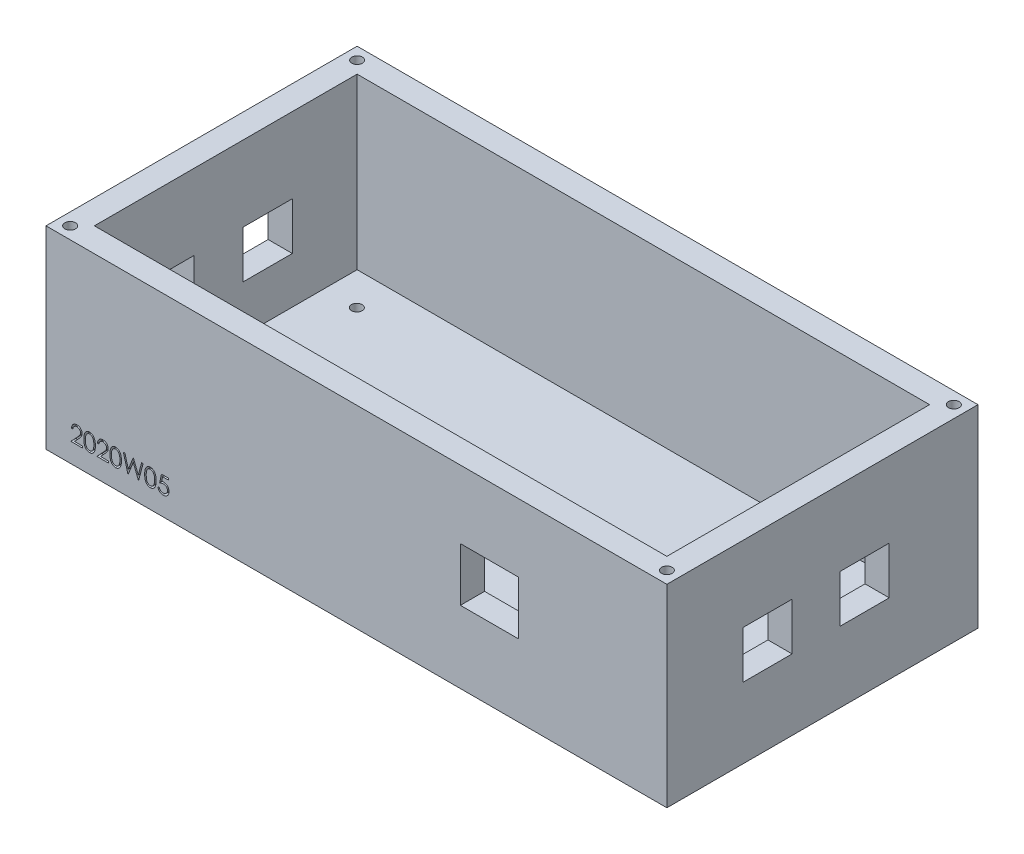
from build123d import *

# Parameters (mm, degrees)
SKETCH1_W           = 128.3
SKETCH1_H           = 64.29
BOSS_EXTRUDE1_DEPTH = 5
SKETCH2_W           = 128.3
SKETCH2_H           = 64.29
SKETCH2_W_2         = 118.3
SKETCH2_H_2         = 54.29
BOSS_EXTRUDE2_DEPTH = 35
SKETCH3_R           = 1.1
CUT_EXTRUDE1_DEPTH  = 6
SKETCH4_R           = 1.1
CUT_EXTRUDE2_DEPTH  = 5
SKETCH5_W           = 10.16
SKETCH5_H           = 9.8
CUT_EXTRUDE3_DEPTH  = 61
SKETCH6_W           = 10.16
SKETCH6_H           = 9.8
CUT_EXTRUDE4_DEPTH  = 61
SKETCH7_W           = 12.03
SKETCH7_H           = 11.05
CUT_EXTRUDE5_DEPTH  = 35
CUT_EXTRUDE6_DEPTH  = 1


with BuildPart() as part:
    # Sketch1 → Boss-Extrude1 (new body)
    with BuildSketch(Plane(origin=(0, 0, 0), x_dir=(1, 0, 0), z_dir=(0, 1, 0))):
        with Locations((-64.15, 32.145)):
            Rectangle(SKETCH1_W, SKETCH1_H)
    extrude(amount=BOSS_EXTRUDE1_DEPTH)

    # Sketch2 → Boss-Extrude2 (add)
    with BuildSketch(Plane(origin=(0, 5, 0), x_dir=(1, 0, 0), z_dir=(0, 1, 0))):
        with Locations((-64.15, 32.145)):
            Rectangle(SKETCH2_W, SKETCH2_H)
        with Locations((-64.15, 32.145)):
            Rectangle(SKETCH2_W_2, SKETCH2_H_2, mode=Mode.SUBTRACT)
    extrude(amount=BOSS_EXTRUDE2_DEPTH)

    # Sketch3 → Cut-Extrude1 (cut, through all)
    with BuildSketch(Plane(origin=(0, 5, 0), x_dir=(1, 0, 0), z_dir=(0, 1, 0))):
        with Locations((-116.54, 52.465)):
            Circle(SKETCH3_R)
        with Locations((-11.76, 52.465)):
            Circle(SKETCH3_R)
        with Locations((-11.76, 11.825)):
            Circle(SKETCH3_R)
        with Locations((-116.54, 11.825)):
            Circle(SKETCH3_R)
    extrude(amount=-CUT_EXTRUDE1_DEPTH, mode=Mode.SUBTRACT)

    # Sketch4 → Cut-Extrude2 (cut)
    with BuildSketch(Plane(origin=(0, 40, 0), x_dir=(1, 0, 0), z_dir=(0, 1, 0))):
        with Locations((-125.8, 61.79)):
            Circle(SKETCH4_R)
        with Locations((-125.8, 2.5)):
            Circle(SKETCH4_R)
        with Locations((-2.5, 2.5)):
            Circle(SKETCH4_R)
        with Locations((-2.5, 61.79)):
            Circle(SKETCH4_R)
    extrude(amount=-CUT_EXTRUDE2_DEPTH, mode=Mode.SUBTRACT)

    # Sketch5 → Cut-Extrude3 (cut)
    with BuildSketch(Plane.ZY.offset(128.3)):
        with Locations((-40.82, 19.5)):
            Rectangle(SKETCH5_W, SKETCH5_H)
        with Locations((-20.5, 19.5)):
            Rectangle(SKETCH5_W, SKETCH5_H)
    extrude(amount=-CUT_EXTRUDE3_DEPTH, mode=Mode.SUBTRACT)

    # Sketch6 → Cut-Extrude4 (cut)
    with BuildSketch(Plane(origin=(0, 0, 0), x_dir=(0, 0, -1), z_dir=(1, 0, 0))):
        with Locations((20.8, 19.5)):
            Rectangle(SKETCH6_W, SKETCH6_H)
        with Locations((40.87, 19.5)):
            Rectangle(SKETCH6_W, SKETCH6_H)
    extrude(amount=-CUT_EXTRUDE4_DEPTH, mode=Mode.SUBTRACT)

    # Sketch7 → Cut-Extrude5 (cut)
    with BuildSketch(Plane.XY):
        with Locations((-36.655, 20.425)):
            Rectangle(SKETCH7_W, SKETCH7_H)
    extrude(amount=-CUT_EXTRUDE5_DEPTH, mode=Mode.SUBTRACT)

    # Sketch8 → Cut-Extrude6 (cut)
    with BuildSketch(Plane.XY):
        with BuildLine():
            Line((-122.716666667, 6.423076923), (-123.030769231, 6.423076923))
            add(Edge.make_bspline(
                [(-123.030769231, 6.423076923), (-123.028722078, 6.464747811), (-123.024701524, 6.546588325), (-123.005873234, 6.665912232), (-122.978932357, 6.779967031), (-122.940840903, 6.887836945), (-122.893534625, 6.990475752), (-122.836804598, 7.087475767), (-122.769610748, 7.178466956), (-122.693404014, 7.262605799), (-122.610635374, 7.33979337), (-122.521329435, 7.406448613), (-122.427484408, 7.462766284), (-122.329385009, 7.509847526), (-122.225924445, 7.545187372), (-122.118041587, 7.571409012), (-122.005262451, 7.587185357), (-121.928422429, 7.588881143), (-121.889342949, 7.58974359)],
                knots=[0, 0, 0, 0, 0.000125083, 0.00024566, 0.000361805, 0.000476223, 0.000588214, 0.000700404, 0.000812728, 0.00092691, 0.001040529, 0.001151727, 0.001260545, 0.001368429, 0.001477521, 0.001587884, 0.001701119, 0.00181831, 0.00181831, 0.00181831, 0.00181831], degree=3))
            add(Edge.make_bspline(
                [(-121.889342949, 7.58974359), (-121.850964875, 7.588845133), (-121.77555333, 7.587079698), (-121.665491316, 7.571918669), (-121.560714021, 7.548173078), (-121.461426255, 7.514857661), (-121.36842019, 7.470073234), (-121.280997145, 7.416275695), (-121.198116335, 7.354055864), (-121.123509551, 7.28080205), (-121.055001472, 7.202599666), (-120.995899217, 7.119111762), (-120.945286053, 7.032882477), (-120.903098373, 6.943254275), (-120.872042234, 6.849383247), (-120.848464026, 6.752636044), (-120.835136613, 6.652011233), (-120.833091189, 6.583904677), (-120.832051282, 6.549278846)],
                knots=[0, 0, 0, 0, 0.000115089, 0.000226145, 0.000332614, 0.000437044, 0.000539592, 0.000641561, 0.000744629, 0.00084975, 0.000954621, 0.001056175, 0.001156101, 0.001254284, 0.001352726, 0.001452208, 0.001552655, 0.001656537, 0.001656537, 0.001656537, 0.001656537], degree=3))
            add(Edge.make_bspline(
                [(-120.832051282, 6.549278846), (-120.833744545, 6.500531012), (-120.837101356, 6.403890798), (-120.865815733, 6.261875935), (-120.910662244, 6.124282516), (-120.964659601, 6.013545214), (-121.019132045, 5.92431172), (-121.068219552, 5.850843015), (-121.125684363, 5.771737547), (-121.192362861, 5.68726021), (-121.266875734, 5.596749304), (-121.349897897, 5.500259509), (-121.442021379, 5.398787739), (-121.50667988, 5.329482138), (-121.540184295, 5.293569712)],
                knots=[0, 0, 0, 0, 0.000146118, 0.000289672, 0.0004329, 0.00057934, 0.000657978, 0.000746456, 0.000844345, 0.000951219, 0.001069268, 0.00119604, 0.001333047, 0.001480391, 0.001480391, 0.001480391, 0.001480391], degree=3))
            Line((-121.540184295, 5.293569712), (-122.415885417, 4.358974359))
            Line((-122.415885417, 4.358974359), (-120.787179487, 4.358974359))
            Line((-120.787179487, 4.358974359), (-120.787179487, 4))
            Line((-120.787179487, 4), (-123.165384615, 4))
            Line((-123.165384615, 4), (-121.808012821, 5.448517628))
            add(Edge.make_bspline(
                [(-121.808012821, 5.448517628), (-121.774964934, 5.483015935), (-121.711486707, 5.549280121), (-121.62170413, 5.646023081), (-121.541065141, 5.735772622), (-121.469047749, 5.818359171), (-121.407214243, 5.894990738), (-121.352342011, 5.963185442), (-121.30837642, 6.025939892), (-121.260661025, 6.098680506), (-121.214447043, 6.187492823), (-121.174734687, 6.296026513), (-121.150519839, 6.407753765), (-121.147615003, 6.483255802), (-121.146153846, 6.521233974)],
                knots=[0, 0, 0, 0, 0.000143319, 0.000275286, 0.00039593, 0.000505287, 0.000603949, 0.000691331, 0.000767782, 0.00083371, 0.000952247, 0.001067137, 0.001179618, 0.001293462, 0.001293462, 0.001293462, 0.001293462], degree=3))
            add(Edge.make_bspline(
                [(-121.146153846, 6.521233974), (-121.146789588, 6.545115373), (-121.148042514, 6.592181023), (-121.159100212, 6.661186782), (-121.175810718, 6.727751596), (-121.199755976, 6.792080215), (-121.231362716, 6.853525867), (-121.269836096, 6.912163347), (-121.31422616, 6.968852313), (-121.365577429, 7.022005611), (-121.421988949, 7.070686816), (-121.481583198, 7.113810902), (-121.544633302, 7.149850012), (-121.610873425, 7.179393509), (-121.680118894, 7.202568891), (-121.752503639, 7.21862747), (-121.827827655, 7.228709954), (-121.879261151, 7.230074126), (-121.90546875, 7.230769231)],
                knots=[0, 0, 0, 0, 7.16e-05, 0.00014111, 0.00020913, 0.00027724, 0.000346538, 0.000415963, 0.000487357, 0.000562233, 0.000637292, 0.000710646, 0.000782564, 0.000854749, 0.000927915, 0.001001225, 0.001076884, 0.001155488, 0.001155488, 0.001155488, 0.001155488], degree=3))
            add(Edge.make_bspline(
                [(-121.90546875, 7.230769231), (-121.932839583, 7.230054199), (-121.986591379, 7.228649993), (-122.065510412, 7.218827329), (-122.140796189, 7.201881489), (-122.212638092, 7.178704814), (-122.281157678, 7.149246266), (-122.346021722, 7.112554521), (-122.407084611, 7.068771028), (-122.464461135, 7.019130471), (-122.517325114, 6.96386287), (-122.56377199, 6.902252907), (-122.604356004, 6.835425492), (-122.639765237, 6.763560941), (-122.668520927, 6.686007161), (-122.690494078, 6.603039456), (-122.707880925, 6.515018075), (-122.713689445, 6.45423299), (-122.716666667, 6.423076923)],
                knots=[0, 0, 0, 0, 8.2106e-05, 0.000161243, 0.000238127, 0.000313291, 0.000387401, 0.000461495, 0.000536397, 0.000612445, 0.000688819, 0.000765383, 0.000843422, 0.000923066, 0.001005373, 0.001091093, 0.001180334, 0.001274175, 0.001274175, 0.001274175, 0.001274175], degree=3))
        make_face()
        with BuildLine():
            add(Edge.make_bspline(
                [(-120.473076923, 5.748597756), (-120.472748905, 5.804695144), (-120.472111725, 5.913665128), (-120.465023304, 6.07244977), (-120.453247962, 6.221410059), (-120.437110589, 6.360553125), (-120.417472609, 6.48991489), (-120.391257122, 6.609149647), (-120.361444319, 6.718809254), (-120.326891874, 6.819251302), (-120.287904085, 6.911829005), (-120.245469824, 6.998254207), (-120.197905029, 7.078396139), (-120.147928116, 7.153533929), (-120.093516045, 7.222437624), (-120.036217254, 7.286080287), (-119.973795378, 7.342991037), (-119.90837237, 7.394837339), (-119.839355905, 7.440286811), (-119.768713239, 7.48031955), (-119.695958133, 7.514519417), (-119.620891951, 7.541409853), (-119.544189393, 7.5636207), (-119.465582326, 7.578809647), (-119.384940962, 7.588366556), (-119.330509527, 7.589280224), (-119.302904647, 7.58974359)],
                knots=[0, 0, 0, 0, 0.000168282, 0.000326891, 0.000476705, 0.00061646, 0.000747059, 0.00086904, 0.000982494, 0.001087814, 0.001187428, 0.001283689, 0.001376399, 0.001466822, 0.001554203, 0.001639568, 0.001723424, 0.001807301, 0.001889751, 0.001971063, 0.002050735, 0.002130583, 0.002210036, 0.002290062, 0.002370508, 0.002453288, 0.002453288, 0.002453288, 0.002453288], degree=3))
            add(Edge.make_bspline(
                [(-119.302904647, 7.58974359), (-119.275069169, 7.589255775), (-119.21971316, 7.588285664), (-119.137872785, 7.578961721), (-119.057923103, 7.563490598), (-118.980204964, 7.541569623), (-118.904079978, 7.514373947), (-118.83014357, 7.48028683), (-118.757936489, 7.440607962), (-118.688606201, 7.393984085), (-118.621391586, 7.342001809), (-118.557943623, 7.28323914), (-118.498256537, 7.218289421), (-118.441581232, 7.147847557), (-118.389525634, 7.070562472), (-118.339952202, 6.987778362), (-118.295580166, 6.898047497), (-118.252845491, 6.80286703), (-118.215958504, 6.699603371), (-118.182692259, 6.58883861), (-118.15581329, 6.469264423), (-118.133424018, 6.341508178), (-118.116079122, 6.205100695), (-118.10344648, 6.060334379), (-118.096773395, 5.907113989), (-118.095516694, 5.80235614), (-118.094871795, 5.748597756)],
                knots=[0, 0, 0, 0, 8.3481e-05, 0.000166017, 0.000246731, 0.000327534, 0.000408041, 0.000488986, 0.000571522, 0.000654944, 0.000739373, 0.000826202, 0.000914021, 0.001003809, 0.001097153, 0.001193347, 0.001293057, 0.001397277, 0.001506176, 0.001621751, 0.001744038, 0.001873599, 0.002010742, 0.002156422, 0.002309427, 0.002470709, 0.002470709, 0.002470709, 0.002470709], degree=3))
            add(Edge.make_bspline(
                [(-118.094871795, 5.748597756), (-118.095523379, 5.695073848), (-118.096792965, 5.590784697), (-118.103371672, 5.438253721), (-118.116330303, 5.294255678), (-118.132540292, 5.158445216), (-118.154991255, 5.031387597), (-118.182596421, 4.912643148), (-118.213246744, 4.801699077), (-118.251081538, 4.699464265), (-118.292492248, 4.604512542), (-118.337547444, 4.515845394), (-118.38581727, 4.432679101), (-118.438406015, 4.355679354), (-118.494459429, 4.284300697), (-118.555177217, 4.219803074), (-118.618847802, 4.160632402), (-118.686260218, 4.107980775), (-118.75667177, 4.06189597), (-118.828630846, 4.02068212), (-118.90341423, 3.987449425), (-118.979327183, 3.958914384), (-119.057455549, 3.937113932), (-119.137701939, 3.922040077), (-119.219658175, 3.911468228), (-119.27505974, 3.910661748), (-119.302904647, 3.91025641)],
                knots=[0, 0, 0, 0, 0.000160581, 0.000312886, 0.000457868, 0.000594226, 0.000723097, 0.000844701, 0.000959884, 0.001068125, 0.001171421, 0.001270505, 0.001366343, 0.001459687, 0.001550023, 0.00163832, 0.001725149, 0.001810562, 0.001894568, 0.001977446, 0.00205903, 0.002139777, 0.00222058, 0.002301983, 0.002384599, 0.00246808, 0.00246808, 0.00246808, 0.00246808], degree=3))
            add(Edge.make_bspline(
                [(-119.302904647, 3.91025641), (-119.330508761, 3.910722766), (-119.384938686, 3.911642328), (-119.465591112, 3.921156059), (-119.543873555, 3.936451562), (-119.620172309, 3.957868166), (-119.694878824, 3.984083003), (-119.766975111, 4.018236686), (-119.837262795, 4.057570755), (-119.905554351, 4.102366177), (-119.970566512, 4.15368786), (-120.032665117, 4.210452149), (-120.090290136, 4.27407556), (-120.143924232, 4.343553483), (-120.19489832, 4.418246725), (-120.241787693, 4.499175098), (-120.285158547, 4.586017709), (-120.324802038, 4.67933562), (-120.359950701, 4.780490547), (-120.390998409, 4.890639726), (-120.415512567, 5.010755362), (-120.436495522, 5.139872729), (-120.453419905, 5.278546659), (-120.464974231, 5.426852438), (-120.472115546, 5.584697647), (-120.472750616, 5.692967421), (-120.473076923, 5.748597756)],
                knots=[0, 0, 0, 0, 8.278e-05, 0.000163226, 0.000243252, 0.00032184, 0.00040079, 0.000480463, 0.00056082, 0.000642298, 0.000725191, 0.000809047, 0.000894412, 0.000982346, 0.001072188, 0.001165503, 0.001262704, 0.001363236, 0.001469448, 0.001583766, 0.001706286, 0.001836995, 0.001976138, 0.002125253, 0.002283161, 0.002450041, 0.002450041, 0.002450041, 0.002450041], degree=3))
        make_face()
        with BuildLine():
            add(Edge.make_bspline(
                [(-120.158974359, 5.75), (-120.158854912, 5.703251301), (-120.158623089, 5.612521256), (-120.152566888, 5.480677995), (-120.144316656, 5.357707667), (-120.133675359, 5.24345413), (-120.11787241, 5.138304118), (-120.100165622, 5.041534435), (-120.078617533, 4.953657197), (-120.053122515, 4.874069387), (-120.024083418, 4.801420318), (-119.992377554, 4.733819103), (-119.958316832, 4.670467167), (-119.920197681, 4.611933558), (-119.878682618, 4.558027394), (-119.834709359, 4.507794562), (-119.786636774, 4.462997581), (-119.720133032, 4.409270726), (-119.632336557, 4.353751592), (-119.521716102, 4.305405502), (-119.408047651, 4.275023046), (-119.330896401, 4.27115929), (-119.292387821, 4.269230769)],
                knots=[0, 0, 0, 0, 0.000140231, 0.000272162, 0.000395845, 0.00050998, 0.000616273, 0.00071473, 0.000805025, 0.000887508, 0.000965234, 0.00103957, 0.001111417, 0.001180842, 0.001248855, 0.001315406, 0.001380877, 0.0014457, 0.001571746, 0.00169106, 0.001806864, 0.001922266, 0.001922266, 0.001922266, 0.001922266], degree=3))
            add(Edge.make_bspline(
                [(-119.292387821, 4.269230769), (-119.253630149, 4.27082855), (-119.176194826, 4.274020813), (-119.063061031, 4.30481955), (-118.95323076, 4.35128909), (-118.86715882, 4.406236595), (-118.801676277, 4.458564925), (-118.754759287, 4.503179573), (-118.711697238, 4.55313544), (-118.670855163, 4.607034736), (-118.633396088, 4.66590722), (-118.59933295, 4.729469796), (-118.568249602, 4.797898973), (-118.550540556, 4.845668713), (-118.541486378, 4.870092147)],
                knots=[0, 0, 0, 0, 0.000116044, 0.000231848, 0.000349318, 0.000472837, 0.000536674, 0.000600645, 0.000666733, 0.000734322, 0.000803367, 0.000875831, 0.000950509, 0.001028633, 0.001028633, 0.001028633, 0.001028633], degree=3))
            add(Edge.make_bspline(
                [(-118.541486378, 4.870092147), (-118.53093461, 4.901321887), (-118.509509997, 4.964731651), (-118.481898222, 5.063095303), (-118.460152823, 5.166298067), (-118.440589457, 5.273723184), (-118.427236401, 5.386162885), (-118.416488588, 5.503269269), (-118.410157901, 5.625130631), (-118.40937315, 5.707925622), (-118.408974359, 5.75)],
                knots=[0, 0, 0, 0, 9.8886e-05, 0.00020078, 0.000306259, 0.000415188, 0.00052824, 0.000645799, 0.000767957, 0.000894177, 0.000894177, 0.000894177, 0.000894177], degree=3))
            add(Edge.make_bspline(
                [(-118.408974359, 5.75), (-118.409524548, 5.792067573), (-118.410600836, 5.874360737), (-118.414714824, 5.994878918), (-118.425338398, 6.109346679), (-118.437137517, 6.218257152), (-118.454534738, 6.321007454), (-118.473292545, 6.418457759), (-118.498493757, 6.509400784), (-118.525413532, 6.595260366), (-118.556223928, 6.675061021), (-118.590139662, 6.749174807), (-118.626361421, 6.817959532), (-118.665703661, 6.881226473), (-118.707699344, 6.939259016), (-118.753456894, 6.990893611), (-118.801161266, 7.037730579), (-118.867978452, 7.091193148), (-118.955452742, 7.145704843), (-119.064298389, 7.195870603), (-119.177569034, 7.224678896), (-119.254142488, 7.228740583), (-119.292387821, 7.230769231)],
                knots=[0, 0, 0, 0, 0.000126219, 0.000246912, 0.000361616, 0.00047102, 0.00057545, 0.000674176, 0.000768567, 0.000858368, 0.000944043, 0.001024988, 0.001102772, 0.001177091, 0.00124833, 0.001317386, 0.001383826, 0.001448649, 0.001573728, 0.001692043, 0.001806995, 0.001921698, 0.001921698, 0.001921698, 0.001921698], degree=3))
            add(Edge.make_bspline(
                [(-119.292387821, 7.230769231), (-119.331098413, 7.228737784), (-119.408590118, 7.22467119), (-119.523038073, 7.195977936), (-119.632742425, 7.14596497), (-119.719985399, 7.091012598), (-119.786849186, 7.038674287), (-119.833931879, 6.993287833), (-119.878078051, 6.943641578), (-119.918745751, 6.889239663), (-119.956835035, 6.830774296), (-119.991816047, 6.767785531), (-120.023333377, 6.699954167), (-120.052417913, 6.627337732), (-120.077990701, 6.547756787), (-120.099084664, 6.459987794), (-120.118571717, 6.363525902), (-120.132366986, 6.257806394), (-120.144630742, 6.14352424), (-120.15251209, 6.020246922), (-120.158643348, 5.888182542), (-120.158861812, 5.796983383), (-120.158974359, 5.75)],
                knots=[0, 0, 0, 0, 0.000116101, 0.000232413, 0.000351368, 0.000476447, 0.000540832, 0.000605795, 0.000672346, 0.000739935, 0.00080936, 0.000881545, 0.00095588, 0.001033607, 0.001116089, 0.001206384, 0.001304286, 0.001411174, 0.001526077, 0.001649061, 0.001781692, 0.001922624, 0.001922624, 0.001922624, 0.001922624], degree=3))
        make_face(mode=Mode.SUBTRACT)
        with BuildLine():
            Line((-117.332051282, 6.423076923), (-117.646153846, 6.423076923))
            add(Edge.make_bspline(
                [(-117.646153846, 6.423076923), (-117.644106693, 6.464747811), (-117.640086139, 6.546588325), (-117.62125785, 6.665912232), (-117.594316973, 6.779967031), (-117.556225519, 6.887836945), (-117.508919241, 6.990475752), (-117.452189213, 7.087475767), (-117.384995363, 7.178466956), (-117.308788629, 7.262605799), (-117.22601999, 7.33979337), (-117.13671405, 7.406448613), (-117.042869023, 7.462766284), (-116.944769624, 7.509847526), (-116.841309061, 7.545187372), (-116.733426203, 7.571409012), (-116.620647066, 7.587185357), (-116.543807044, 7.588881143), (-116.504727564, 7.58974359)],
                knots=[0, 0, 0, 0, 0.000125083, 0.00024566, 0.000361805, 0.000476223, 0.000588214, 0.000700404, 0.000812728, 0.00092691, 0.001040529, 0.001151727, 0.001260545, 0.001368429, 0.001477521, 0.001587884, 0.001701119, 0.00181831, 0.00181831, 0.00181831, 0.00181831], degree=3))
            add(Edge.make_bspline(
                [(-116.504727564, 7.58974359), (-116.46634949, 7.588845133), (-116.390937945, 7.587079698), (-116.280875931, 7.571918669), (-116.176098636, 7.548173078), (-116.07681087, 7.514857661), (-115.983804805, 7.470073234), (-115.896381761, 7.416275695), (-115.81350095, 7.354055864), (-115.738894166, 7.28080205), (-115.670386087, 7.202599666), (-115.611283832, 7.119111762), (-115.560670669, 7.032882477), (-115.518482989, 6.943254275), (-115.48742685, 6.849383247), (-115.463848642, 6.752636044), (-115.450521228, 6.652011233), (-115.448475805, 6.583904677), (-115.447435897, 6.549278846)],
                knots=[0, 0, 0, 0, 0.000115089, 0.000226145, 0.000332614, 0.000437044, 0.000539592, 0.000641561, 0.000744629, 0.00084975, 0.000954621, 0.001056175, 0.001156101, 0.001254284, 0.001352726, 0.001452208, 0.001552655, 0.001656537, 0.001656537, 0.001656537, 0.001656537], degree=3))
            add(Edge.make_bspline(
                [(-115.447435897, 6.549278846), (-115.44912916, 6.500531012), (-115.452485972, 6.403890798), (-115.481200348, 6.261875935), (-115.526046859, 6.124282516), (-115.580044216, 6.013545214), (-115.63451666, 5.92431172), (-115.683604168, 5.850843015), (-115.741068979, 5.771737547), (-115.807747477, 5.68726021), (-115.882260349, 5.596749304), (-115.965282512, 5.500259509), (-116.057405994, 5.398787739), (-116.122064495, 5.329482138), (-116.15556891, 5.293569712)],
                knots=[0, 0, 0, 0, 0.000146118, 0.000289672, 0.0004329, 0.00057934, 0.000657978, 0.000746456, 0.000844345, 0.000951219, 0.001069268, 0.00119604, 0.001333047, 0.001480391, 0.001480391, 0.001480391, 0.001480391], degree=3))
            Line((-116.15556891, 5.293569712), (-117.031270032, 4.358974359))
            Line((-117.031270032, 4.358974359), (-115.402564103, 4.358974359))
            Line((-115.402564103, 4.358974359), (-115.402564103, 4))
            Line((-115.402564103, 4), (-117.780769231, 4))
            Line((-117.780769231, 4), (-116.423397436, 5.448517628))
            add(Edge.make_bspline(
                [(-116.423397436, 5.448517628), (-116.390349549, 5.483015935), (-116.326871322, 5.549280121), (-116.237088745, 5.646023081), (-116.156449757, 5.735772622), (-116.084432364, 5.818359171), (-116.022598859, 5.894990738), (-115.967726627, 5.963185442), (-115.923761036, 6.025939892), (-115.87604564, 6.098680506), (-115.829831659, 6.187492823), (-115.790119303, 6.296026513), (-115.765904454, 6.407753765), (-115.762999619, 6.483255802), (-115.761538462, 6.521233974)],
                knots=[0, 0, 0, 0, 0.000143319, 0.000275286, 0.00039593, 0.000505287, 0.000603949, 0.000691331, 0.000767782, 0.00083371, 0.000952247, 0.001067137, 0.001179618, 0.001293462, 0.001293462, 0.001293462, 0.001293462], degree=3))
            add(Edge.make_bspline(
                [(-115.761538462, 6.521233974), (-115.762174204, 6.545115373), (-115.76342713, 6.592181023), (-115.774484827, 6.661186782), (-115.791195333, 6.727751596), (-115.815140591, 6.792080215), (-115.846747332, 6.853525867), (-115.885220711, 6.912163347), (-115.929610775, 6.968852313), (-115.980962044, 7.022005611), (-116.037373564, 7.070686816), (-116.096967814, 7.113810902), (-116.160017918, 7.149850012), (-116.22625804, 7.179393509), (-116.295503509, 7.202568891), (-116.367888255, 7.21862747), (-116.443212271, 7.228709954), (-116.494645767, 7.230074126), (-116.520853365, 7.230769231)],
                knots=[0, 0, 0, 0, 7.16e-05, 0.00014111, 0.00020913, 0.00027724, 0.000346538, 0.000415963, 0.000487357, 0.000562233, 0.000637292, 0.000710646, 0.000782564, 0.000854749, 0.000927915, 0.001001225, 0.001076884, 0.001155488, 0.001155488, 0.001155488, 0.001155488], degree=3))
            add(Edge.make_bspline(
                [(-116.520853365, 7.230769231), (-116.548224198, 7.230054199), (-116.601975994, 7.228649993), (-116.680895027, 7.218827329), (-116.756180805, 7.201881489), (-116.828022708, 7.178704814), (-116.896542294, 7.149246266), (-116.961406338, 7.112554521), (-117.022469227, 7.068771028), (-117.07984575, 7.019130471), (-117.132709729, 6.96386287), (-117.179156605, 6.902252907), (-117.219740619, 6.835425492), (-117.255149853, 6.763560941), (-117.283905543, 6.686007161), (-117.305878693, 6.603039456), (-117.32326554, 6.515018075), (-117.329074061, 6.45423299), (-117.332051282, 6.423076923)],
                knots=[0, 0, 0, 0, 8.2106e-05, 0.000161243, 0.000238127, 0.000313291, 0.000387401, 0.000461495, 0.000536397, 0.000612445, 0.000688819, 0.000765383, 0.000843422, 0.000923066, 0.001005373, 0.001091093, 0.001180334, 0.001274175, 0.001274175, 0.001274175, 0.001274175], degree=3))
        make_face()
        with BuildLine():
            add(Edge.make_bspline(
                [(-115.088461538, 5.748597756), (-115.08813352, 5.804695144), (-115.08749634, 5.913665128), (-115.080407919, 6.07244977), (-115.068632577, 6.221410059), (-115.052495204, 6.360553125), (-115.032857224, 6.48991489), (-115.006641737, 6.609149647), (-114.976828935, 6.718809254), (-114.942276489, 6.819251302), (-114.9032887, 6.911829005), (-114.860854439, 6.998254207), (-114.813289645, 7.078396139), (-114.763312732, 7.153533929), (-114.70890066, 7.222437624), (-114.65160187, 7.286080287), (-114.589179993, 7.342991037), (-114.523756985, 7.394837339), (-114.454740521, 7.440286811), (-114.384097855, 7.48031955), (-114.311342749, 7.514519417), (-114.236276566, 7.541409853), (-114.159574008, 7.5636207), (-114.080966941, 7.578809647), (-114.000325577, 7.588366556), (-113.945894143, 7.589280224), (-113.918289263, 7.58974359)],
                knots=[0, 0, 0, 0, 0.000168282, 0.000326891, 0.000476705, 0.00061646, 0.000747059, 0.00086904, 0.000982494, 0.001087814, 0.001187428, 0.001283689, 0.001376399, 0.001466822, 0.001554203, 0.001639568, 0.001723424, 0.001807301, 0.001889751, 0.001971063, 0.002050735, 0.002130583, 0.002210036, 0.002290062, 0.002370508, 0.002453288, 0.002453288, 0.002453288, 0.002453288], degree=3))
            add(Edge.make_bspline(
                [(-113.918289263, 7.58974359), (-113.890453784, 7.589255775), (-113.835097775, 7.588285664), (-113.7532574, 7.578961721), (-113.673307718, 7.563490598), (-113.59558958, 7.541569623), (-113.519464593, 7.514373947), (-113.445528186, 7.48028683), (-113.373321104, 7.440607962), (-113.303990817, 7.393984085), (-113.236776201, 7.342001809), (-113.173328238, 7.28323914), (-113.113641152, 7.218289421), (-113.056965847, 7.147847557), (-113.00491025, 7.070562472), (-112.955336817, 6.987778362), (-112.910964782, 6.898047497), (-112.868230106, 6.80286703), (-112.83134312, 6.699603371), (-112.798076874, 6.58883861), (-112.771197906, 6.469264423), (-112.748808633, 6.341508178), (-112.731463738, 6.205100695), (-112.718831095, 6.060334379), (-112.71215801, 5.907113989), (-112.710901309, 5.80235614), (-112.71025641, 5.748597756)],
                knots=[0, 0, 0, 0, 8.3481e-05, 0.000166017, 0.000246731, 0.000327534, 0.000408041, 0.000488986, 0.000571522, 0.000654944, 0.000739373, 0.000826202, 0.000914021, 0.001003809, 0.001097153, 0.001193347, 0.001293057, 0.001397277, 0.001506176, 0.001621751, 0.001744038, 0.001873599, 0.002010742, 0.002156422, 0.002309427, 0.002470709, 0.002470709, 0.002470709, 0.002470709], degree=3))
            add(Edge.make_bspline(
                [(-112.71025641, 5.748597756), (-112.710907995, 5.695073848), (-112.712177581, 5.590784697), (-112.718756287, 5.438253721), (-112.731714919, 5.294255678), (-112.747924907, 5.158445216), (-112.77037587, 5.031387597), (-112.797981036, 4.912643148), (-112.828631359, 4.801699077), (-112.866466153, 4.699464265), (-112.907876863, 4.604512542), (-112.95293206, 4.515845394), (-113.001201886, 4.432679101), (-113.053790631, 4.355679354), (-113.109844044, 4.284300697), (-113.170561833, 4.219803074), (-113.234232418, 4.160632402), (-113.301644834, 4.107980775), (-113.372056385, 4.06189597), (-113.444015462, 4.02068212), (-113.518798845, 3.987449425), (-113.594711798, 3.958914384), (-113.672840164, 3.937113932), (-113.753086555, 3.922040077), (-113.835042791, 3.911468228), (-113.890444356, 3.910661748), (-113.918289263, 3.91025641)],
                knots=[0, 0, 0, 0, 0.000160581, 0.000312886, 0.000457868, 0.000594226, 0.000723097, 0.000844701, 0.000959884, 0.001068125, 0.001171421, 0.001270505, 0.001366343, 0.001459687, 0.001550023, 0.00163832, 0.001725149, 0.001810562, 0.001894568, 0.001977446, 0.00205903, 0.002139777, 0.00222058, 0.002301983, 0.002384599, 0.00246808, 0.00246808, 0.00246808, 0.00246808], degree=3))
            add(Edge.make_bspline(
                [(-113.918289263, 3.91025641), (-113.945893377, 3.910722766), (-114.000323302, 3.911642328), (-114.080975727, 3.921156059), (-114.15925817, 3.936451562), (-114.235556924, 3.957868166), (-114.31026344, 3.984083003), (-114.382359726, 4.018236686), (-114.45264741, 4.057570755), (-114.520938966, 4.102366177), (-114.585951127, 4.15368786), (-114.648049732, 4.210452149), (-114.705674751, 4.27407556), (-114.759308847, 4.343553483), (-114.810282935, 4.418246725), (-114.857172309, 4.499175098), (-114.900543163, 4.586017709), (-114.940186653, 4.67933562), (-114.975335317, 4.780490547), (-115.006383025, 4.890639726), (-115.030897182, 5.010755362), (-115.051880138, 5.139872729), (-115.068804521, 5.278546659), (-115.080358846, 5.426852438), (-115.087500161, 5.584697647), (-115.088135232, 5.692967421), (-115.088461538, 5.748597756)],
                knots=[0, 0, 0, 0, 8.278e-05, 0.000163226, 0.000243252, 0.00032184, 0.00040079, 0.000480463, 0.00056082, 0.000642298, 0.000725191, 0.000809047, 0.000894412, 0.000982346, 0.001072188, 0.001165503, 0.001262704, 0.001363236, 0.001469448, 0.001583766, 0.001706286, 0.001836995, 0.001976138, 0.002125253, 0.002283161, 0.002450041, 0.002450041, 0.002450041, 0.002450041], degree=3))
        make_face()
        with BuildLine():
            add(Edge.make_bspline(
                [(-114.774358974, 5.75), (-114.774239527, 5.703251301), (-114.774007704, 5.612521256), (-114.767951503, 5.480677995), (-114.759701271, 5.357707667), (-114.749059974, 5.24345413), (-114.733257026, 5.138304118), (-114.715550238, 5.041534435), (-114.694002148, 4.953657197), (-114.66850713, 4.874069387), (-114.639468034, 4.801420318), (-114.60776217, 4.733819103), (-114.573701447, 4.670467167), (-114.535582296, 4.611933558), (-114.494067233, 4.558027394), (-114.450093974, 4.507794562), (-114.40202139, 4.462997581), (-114.335517647, 4.409270726), (-114.247721173, 4.353751592), (-114.137100718, 4.305405502), (-114.023432267, 4.275023046), (-113.946281016, 4.27115929), (-113.907772436, 4.269230769)],
                knots=[0, 0, 0, 0, 0.000140231, 0.000272162, 0.000395845, 0.00050998, 0.000616273, 0.00071473, 0.000805025, 0.000887508, 0.000965234, 0.00103957, 0.001111417, 0.001180842, 0.001248855, 0.001315406, 0.001380877, 0.0014457, 0.001571746, 0.00169106, 0.001806864, 0.001922266, 0.001922266, 0.001922266, 0.001922266], degree=3))
            add(Edge.make_bspline(
                [(-113.907772436, 4.269230769), (-113.869014764, 4.27082855), (-113.791579441, 4.274020813), (-113.678445646, 4.30481955), (-113.568615376, 4.35128909), (-113.482543436, 4.406236595), (-113.417060892, 4.458564925), (-113.370143902, 4.503179573), (-113.327081854, 4.55313544), (-113.286239779, 4.607034736), (-113.248780703, 4.66590722), (-113.214717565, 4.729469796), (-113.183634218, 4.797898973), (-113.165925172, 4.845668713), (-113.156870994, 4.870092147)],
                knots=[0, 0, 0, 0, 0.000116044, 0.000231848, 0.000349318, 0.000472837, 0.000536674, 0.000600645, 0.000666733, 0.000734322, 0.000803367, 0.000875831, 0.000950509, 0.001028633, 0.001028633, 0.001028633, 0.001028633], degree=3))
            add(Edge.make_bspline(
                [(-113.156870994, 4.870092147), (-113.146319226, 4.901321887), (-113.124894612, 4.964731651), (-113.097282838, 5.063095303), (-113.075537438, 5.166298067), (-113.055974073, 5.273723184), (-113.042621017, 5.386162885), (-113.031873204, 5.503269269), (-113.025542517, 5.625130631), (-113.024757766, 5.707925622), (-113.024358974, 5.75)],
                knots=[0, 0, 0, 0, 9.8886e-05, 0.00020078, 0.000306259, 0.000415188, 0.00052824, 0.000645799, 0.000767957, 0.000894177, 0.000894177, 0.000894177, 0.000894177], degree=3))
            add(Edge.make_bspline(
                [(-113.024358974, 5.75), (-113.024909164, 5.792067573), (-113.025985451, 5.874360737), (-113.030099439, 5.994878918), (-113.040723014, 6.109346679), (-113.052522132, 6.218257152), (-113.069919353, 6.321007454), (-113.08867716, 6.418457759), (-113.113878373, 6.509400784), (-113.140798148, 6.595260366), (-113.171608543, 6.675061021), (-113.205524277, 6.749174807), (-113.241746036, 6.817959532), (-113.281088277, 6.881226473), (-113.32308396, 6.939259016), (-113.368841509, 6.990893611), (-113.416545882, 7.037730579), (-113.483363068, 7.091193148), (-113.570837357, 7.145704843), (-113.679683005, 7.195870603), (-113.792953649, 7.224678896), (-113.869527103, 7.228740583), (-113.907772436, 7.230769231)],
                knots=[0, 0, 0, 0, 0.000126219, 0.000246912, 0.000361616, 0.00047102, 0.00057545, 0.000674176, 0.000768567, 0.000858368, 0.000944043, 0.001024988, 0.001102772, 0.001177091, 0.00124833, 0.001317386, 0.001383826, 0.001448649, 0.001573728, 0.001692043, 0.001806995, 0.001921698, 0.001921698, 0.001921698, 0.001921698], degree=3))
            add(Edge.make_bspline(
                [(-113.907772436, 7.230769231), (-113.946483028, 7.228737784), (-114.023974734, 7.22467119), (-114.138422688, 7.195977936), (-114.24812704, 7.14596497), (-114.335370015, 7.091012598), (-114.402233801, 7.038674287), (-114.449316495, 6.993287833), (-114.493462667, 6.943641578), (-114.534130367, 6.889239663), (-114.57221965, 6.830774296), (-114.607200663, 6.767785531), (-114.638717992, 6.699954167), (-114.667802529, 6.627337732), (-114.693375317, 6.547756787), (-114.71446928, 6.459987794), (-114.733956333, 6.363525902), (-114.747751602, 6.257806394), (-114.760015358, 6.14352424), (-114.767896705, 6.020246922), (-114.774027963, 5.888182542), (-114.774246427, 5.796983383), (-114.774358974, 5.75)],
                knots=[0, 0, 0, 0, 0.000116101, 0.000232413, 0.000351368, 0.000476447, 0.000540832, 0.000605795, 0.000672346, 0.000739935, 0.00080936, 0.000881545, 0.00095588, 0.001033607, 0.001116089, 0.001206384, 0.001304286, 0.001411174, 0.001526077, 0.001649061, 0.001781692, 0.001922624, 0.001922624, 0.001922624, 0.001922624], degree=3))
        make_face(mode=Mode.SUBTRACT)
        Polygon((-112.306410256, 7.5), (-111.981790865, 7.5), (-111.296794872, 4.933193109), (-110.278064904, 7.5), (-110.232491987, 7.5), (-109.232692308, 4.950721154), (-108.544190705, 7.5), (-108.223076923, 7.5), (-109.166786859, 4), (-109.211658654, 4), (-110.26474359, 6.676883013), (-111.330448718, 4), (-111.375320513, 4), align=None)
        with BuildLine():
            add(Edge.make_bspline(
                [(-107.908974359, 5.748597756), (-107.908646341, 5.804695144), (-107.908009161, 5.913665128), (-107.90092074, 6.07244977), (-107.889145398, 6.221410059), (-107.873008025, 6.360553125), (-107.853370044, 6.48991489), (-107.827154558, 6.609149647), (-107.797341755, 6.718809254), (-107.762789309, 6.819251302), (-107.72380152, 6.911829005), (-107.68136726, 6.998254207), (-107.633802465, 7.078396139), (-107.583825552, 7.153533929), (-107.529413481, 7.222437624), (-107.47211469, 7.286080287), (-107.409692814, 7.342991037), (-107.344269806, 7.394837339), (-107.275253341, 7.440286811), (-107.204610675, 7.48031955), (-107.131855569, 7.514519417), (-107.056789386, 7.541409853), (-106.980086829, 7.5636207), (-106.901479762, 7.578809647), (-106.820838398, 7.588366556), (-106.766406963, 7.589280224), (-106.738802083, 7.58974359)],
                knots=[0, 0, 0, 0, 0.000168282, 0.000326891, 0.000476705, 0.00061646, 0.000747059, 0.00086904, 0.000982494, 0.001087814, 0.001187428, 0.001283689, 0.001376399, 0.001466822, 0.001554203, 0.001639568, 0.001723424, 0.001807301, 0.001889751, 0.001971063, 0.002050735, 0.002130583, 0.002210036, 0.002290062, 0.002370508, 0.002453288, 0.002453288, 0.002453288, 0.002453288], degree=3))
            add(Edge.make_bspline(
                [(-106.738802083, 7.58974359), (-106.710966605, 7.589255775), (-106.655610596, 7.588285664), (-106.573770221, 7.578961721), (-106.493820539, 7.563490598), (-106.4161024, 7.541569623), (-106.339977414, 7.514373947), (-106.266041006, 7.48028683), (-106.193833925, 7.440607962), (-106.124503637, 7.393984085), (-106.057289022, 7.342001809), (-105.993841059, 7.28323914), (-105.934153973, 7.218289421), (-105.877478667, 7.147847557), (-105.82542307, 7.070562472), (-105.775849638, 6.987778362), (-105.731477602, 6.898047497), (-105.688742927, 6.80286703), (-105.65185594, 6.699603371), (-105.618589695, 6.58883861), (-105.591710726, 6.469264423), (-105.569321454, 6.341508178), (-105.551976558, 6.205100695), (-105.539343916, 6.060334379), (-105.532670831, 5.907113989), (-105.53141413, 5.80235614), (-105.530769231, 5.748597756)],
                knots=[0, 0, 0, 0, 8.3481e-05, 0.000166017, 0.000246731, 0.000327534, 0.000408041, 0.000488986, 0.000571522, 0.000654944, 0.000739373, 0.000826202, 0.000914021, 0.001003809, 0.001097153, 0.001193347, 0.001293057, 0.001397277, 0.001506176, 0.001621751, 0.001744038, 0.001873599, 0.002010742, 0.002156422, 0.002309427, 0.002470709, 0.002470709, 0.002470709, 0.002470709], degree=3))
            add(Edge.make_bspline(
                [(-105.530769231, 5.748597756), (-105.531420815, 5.695073848), (-105.532690401, 5.590784697), (-105.539269108, 5.438253721), (-105.552227739, 5.294255678), (-105.568437727, 5.158445216), (-105.59088869, 5.031387597), (-105.618493857, 4.912643148), (-105.64914418, 4.801699077), (-105.686978974, 4.699464265), (-105.728389684, 4.604512542), (-105.77344488, 4.515845394), (-105.821714706, 4.432679101), (-105.874303451, 4.355679354), (-105.930356864, 4.284300697), (-105.991074653, 4.219803074), (-106.054745238, 4.160632402), (-106.122157654, 4.107980775), (-106.192569205, 4.06189597), (-106.264528282, 4.02068212), (-106.339311666, 3.987449425), (-106.415224618, 3.958914384), (-106.493352985, 3.937113932), (-106.573599375, 3.922040077), (-106.655555611, 3.911468228), (-106.710957176, 3.910661748), (-106.738802083, 3.91025641)],
                knots=[0, 0, 0, 0, 0.000160581, 0.000312886, 0.000457868, 0.000594226, 0.000723097, 0.000844701, 0.000959884, 0.001068125, 0.001171421, 0.001270505, 0.001366343, 0.001459687, 0.001550023, 0.00163832, 0.001725149, 0.001810562, 0.001894568, 0.001977446, 0.00205903, 0.002139777, 0.00222058, 0.002301983, 0.002384599, 0.00246808, 0.00246808, 0.00246808, 0.00246808], degree=3))
            add(Edge.make_bspline(
                [(-106.738802083, 3.91025641), (-106.766406197, 3.910722766), (-106.820836122, 3.911642328), (-106.901488548, 3.921156059), (-106.979770991, 3.936451562), (-107.056069745, 3.957868166), (-107.13077626, 3.984083003), (-107.202872547, 4.018236686), (-107.27316023, 4.057570755), (-107.341451786, 4.102366177), (-107.406463947, 4.15368786), (-107.468562553, 4.210452149), (-107.526187572, 4.27407556), (-107.579821668, 4.343553483), (-107.630795756, 4.418246725), (-107.677685129, 4.499175098), (-107.721055983, 4.586017709), (-107.760699474, 4.67933562), (-107.795848137, 4.780490547), (-107.826895845, 4.890639726), (-107.851410003, 5.010755362), (-107.872392958, 5.139872729), (-107.889317341, 5.278546659), (-107.900871667, 5.426852438), (-107.908012982, 5.584697647), (-107.908648052, 5.692967421), (-107.908974359, 5.748597756)],
                knots=[0, 0, 0, 0, 8.278e-05, 0.000163226, 0.000243252, 0.00032184, 0.00040079, 0.000480463, 0.00056082, 0.000642298, 0.000725191, 0.000809047, 0.000894412, 0.000982346, 0.001072188, 0.001165503, 0.001262704, 0.001363236, 0.001469448, 0.001583766, 0.001706286, 0.001836995, 0.001976138, 0.002125253, 0.002283161, 0.002450041, 0.002450041, 0.002450041, 0.002450041], degree=3))
        make_face()
        with BuildLine():
            add(Edge.make_bspline(
                [(-107.594871795, 5.75), (-107.594752348, 5.703251301), (-107.594520525, 5.612521256), (-107.588464324, 5.480677995), (-107.580214092, 5.357707667), (-107.569572795, 5.24345413), (-107.553769846, 5.138304118), (-107.536063058, 5.041534435), (-107.514514969, 4.953657197), (-107.489019951, 4.874069387), (-107.459980854, 4.801420318), (-107.42827499, 4.733819103), (-107.394214267, 4.670467167), (-107.356095117, 4.611933558), (-107.314580054, 4.558027394), (-107.270606795, 4.507794562), (-107.22253421, 4.462997581), (-107.156030468, 4.409270726), (-107.068233993, 4.353751592), (-106.957613538, 4.305405502), (-106.843945087, 4.275023046), (-106.766793837, 4.27115929), (-106.728285256, 4.269230769)],
                knots=[0, 0, 0, 0, 0.000140231, 0.000272162, 0.000395845, 0.00050998, 0.000616273, 0.00071473, 0.000805025, 0.000887508, 0.000965234, 0.00103957, 0.001111417, 0.001180842, 0.001248855, 0.001315406, 0.001380877, 0.0014457, 0.001571746, 0.00169106, 0.001806864, 0.001922266, 0.001922266, 0.001922266, 0.001922266], degree=3))
            add(Edge.make_bspline(
                [(-106.728285256, 4.269230769), (-106.689527585, 4.27082855), (-106.612092262, 4.274020813), (-106.498958466, 4.30481955), (-106.389128196, 4.35128909), (-106.303056256, 4.406236595), (-106.237573713, 4.458564925), (-106.190656722, 4.503179573), (-106.147594674, 4.55313544), (-106.106752599, 4.607034736), (-106.069293523, 4.66590722), (-106.035230386, 4.729469796), (-106.004147038, 4.797898973), (-105.986437992, 4.845668713), (-105.977383814, 4.870092147)],
                knots=[0, 0, 0, 0, 0.000116044, 0.000231848, 0.000349318, 0.000472837, 0.000536674, 0.000600645, 0.000666733, 0.000734322, 0.000803367, 0.000875831, 0.000950509, 0.001028633, 0.001028633, 0.001028633, 0.001028633], degree=3))
            add(Edge.make_bspline(
                [(-105.977383814, 4.870092147), (-105.966832046, 4.901321887), (-105.945407432, 4.964731651), (-105.917795658, 5.063095303), (-105.896050259, 5.166298067), (-105.876486893, 5.273723184), (-105.863133837, 5.386162885), (-105.852386024, 5.503269269), (-105.846055337, 5.625130631), (-105.845270586, 5.707925622), (-105.844871795, 5.75)],
                knots=[0, 0, 0, 0, 9.8886e-05, 0.00020078, 0.000306259, 0.000415188, 0.00052824, 0.000645799, 0.000767957, 0.000894177, 0.000894177, 0.000894177, 0.000894177], degree=3))
            add(Edge.make_bspline(
                [(-105.844871795, 5.75), (-105.845421984, 5.792067573), (-105.846498272, 5.874360737), (-105.85061226, 5.994878918), (-105.861235834, 6.109346679), (-105.873034953, 6.218257152), (-105.890432174, 6.321007454), (-105.909189981, 6.418457759), (-105.934391193, 6.509400784), (-105.961310968, 6.595260366), (-105.992121364, 6.675061021), (-106.026037098, 6.749174807), (-106.062258857, 6.817959532), (-106.101601097, 6.881226473), (-106.14359678, 6.939259016), (-106.189354329, 6.990893611), (-106.237058702, 7.037730579), (-106.303875888, 7.091193148), (-106.391350178, 7.145704843), (-106.500195825, 7.195870603), (-106.613466469, 7.224678896), (-106.690039924, 7.228740583), (-106.728285256, 7.230769231)],
                knots=[0, 0, 0, 0, 0.000126219, 0.000246912, 0.000361616, 0.00047102, 0.00057545, 0.000674176, 0.000768567, 0.000858368, 0.000944043, 0.001024988, 0.001102772, 0.001177091, 0.00124833, 0.001317386, 0.001383826, 0.001448649, 0.001573728, 0.001692043, 0.001806995, 0.001921698, 0.001921698, 0.001921698, 0.001921698], degree=3))
            add(Edge.make_bspline(
                [(-106.728285256, 7.230769231), (-106.766995848, 7.228737784), (-106.844487554, 7.22467119), (-106.958935509, 7.195977936), (-107.06863986, 7.14596497), (-107.155882835, 7.091012598), (-107.222746622, 7.038674287), (-107.269829315, 6.993287833), (-107.313975487, 6.943641578), (-107.354643187, 6.889239663), (-107.392732471, 6.830774296), (-107.427713483, 6.767785531), (-107.459230813, 6.699954167), (-107.488315349, 6.627337732), (-107.513888137, 6.547756787), (-107.5349821, 6.459987794), (-107.554469153, 6.363525902), (-107.568264422, 6.257806394), (-107.580528178, 6.14352424), (-107.588409526, 6.020246922), (-107.594540783, 5.888182542), (-107.594759248, 5.796983383), (-107.594871795, 5.75)],
                knots=[0, 0, 0, 0, 0.000116101, 0.000232413, 0.000351368, 0.000476447, 0.000540832, 0.000605795, 0.000672346, 0.000739935, 0.00080936, 0.000881545, 0.00095588, 0.001033607, 0.001116089, 0.001206384, 0.001304286, 0.001411174, 0.001526077, 0.001649061, 0.001781692, 0.001922624, 0.001922624, 0.001922624, 0.001922624], degree=3))
        make_face(mode=Mode.SUBTRACT)
        with BuildLine():
            Line((-103.017948718, 7.5), (-103.017948718, 7.141025641))
            Line((-103.017948718, 7.141025641), (-104.208453526, 7.141025641))
            Line((-104.208453526, 7.141025641), (-104.397055288, 6.220452724))
            add(Edge.make_bspline(
                [(-104.397055288, 6.220452724), (-104.359999414, 6.230682996), (-104.288209518, 6.25050253), (-104.182249657, 6.2725083), (-104.081657454, 6.285773744), (-104.016382083, 6.287585055), (-103.984795673, 6.288461538)],
                knots=[0, 0, 0, 0, 0.000115302, 0.000223379, 0.000324431, 0.000419176, 0.000419176, 0.000419176, 0.000419176], degree=3))
            add(Edge.make_bspline(
                [(-103.984795673, 6.288461538), (-103.945711933, 6.287615603), (-103.868863536, 6.285952282), (-103.756424589, 6.269980432), (-103.649091696, 6.244840518), (-103.547089326, 6.209719996), (-103.450228775, 6.164810263), (-103.359401214, 6.108710322), (-103.273243301, 6.043176991), (-103.193300707, 5.967831979), (-103.120776398, 5.884910363), (-103.057010409, 5.795752492), (-103.002847818, 5.701224829), (-102.959287064, 5.600424221), (-102.924502729, 5.494465067), (-102.901350734, 5.382232485), (-102.885934025, 5.264784365), (-102.884211639, 5.184479795), (-102.883333333, 5.143529647)],
                knots=[0, 0, 0, 0, 0.00011719, 0.000230425, 0.000339944, 0.000447481, 0.000553499, 0.000659556, 0.000767111, 0.000877722, 0.000988528, 0.001097091, 0.001206056, 0.001314692, 0.001425996, 0.001539995, 0.001658004, 0.001780798, 0.001780798, 0.001780798, 0.001780798], degree=3))
            add(Edge.make_bspline(
                [(-102.883333333, 5.143529647), (-102.883998409, 5.115007427), (-102.885319571, 5.05834844), (-102.892038159, 4.974204239), (-102.904973875, 4.891841406), (-102.922341599, 4.811249014), (-102.944884017, 4.732579642), (-102.972173071, 4.655608114), (-103.005569098, 4.580813507), (-103.042200474, 4.507488112), (-103.083446952, 4.437289605), (-103.129225459, 4.371640618), (-103.17759095, 4.309556337), (-103.229632336, 4.251702604), (-103.285833331, 4.198459586), (-103.345513298, 4.149511304), (-103.408196017, 4.104029974), (-103.474851259, 4.063861779), (-103.543993742, 4.026898823), (-103.616621959, 3.996575285), (-103.69108266, 3.969464757), (-103.768447535, 3.94785523), (-103.848541348, 3.930922675), (-103.931496123, 3.919422075), (-104.016876793, 3.911045637), (-104.074751806, 3.91052128), (-104.103986378, 3.91025641)],
                knots=[0, 0, 0, 0, 8.5583e-05, 0.000170009, 0.000253005, 0.000335518, 0.000417186, 0.000498352, 0.000580291, 0.000662755, 0.000744161, 0.000824288, 0.000902692, 0.000980133, 0.001057498, 0.001134702, 0.00121156, 0.001289599, 0.001368002, 0.001446531, 0.001525481, 0.001605609, 0.001687289, 0.001770875, 0.001856759, 0.001944425, 0.001944425, 0.001944425, 0.001944425], degree=3))
            add(Edge.make_bspline(
                [(-104.103986378, 3.91025641), (-104.138860559, 3.910947248), (-104.20747139, 3.91230639), (-104.307991957, 3.926524876), (-104.404706562, 3.946888792), (-104.496836664, 3.977525062), (-104.585207927, 4.015912357), (-104.668630645, 4.064428528), (-104.749236421, 4.119407632), (-104.823748458, 4.184287985), (-104.892904571, 4.255203667), (-104.95481108, 4.332161308), (-105.009944657, 4.41389075), (-105.057422404, 4.500788904), (-105.097920425, 4.592627435), (-105.129735413, 4.689750436), (-105.155413768, 4.79165044), (-105.166277189, 4.86180395), (-105.171794872, 4.897435897)],
                knots=[0, 0, 0, 0, 0.000104552, 0.000205693, 0.000304023, 0.000400691, 0.00049644, 0.000592535, 0.000689779, 0.000788716, 0.000888377, 0.000986596, 0.001084603, 0.001183757, 0.001283279, 0.001385267, 0.001490017, 0.001598135, 0.001598135, 0.001598135, 0.001598135], degree=3))
            Line((-105.171794872, 4.897435897), (-104.857692308, 4.897435897))
            add(Edge.make_bspline(
                [(-104.857692308, 4.897435897), (-104.84996375, 4.864059445), (-104.835109034, 4.79990805), (-104.802503285, 4.709776709), (-104.76263741, 4.629457485), (-104.715233061, 4.557887902), (-104.658683031, 4.495478905), (-104.594153602, 4.439861843), (-104.521805879, 4.389686713), (-104.441412649, 4.347863946), (-104.35659957, 4.312195193), (-104.26783236, 4.288443498), (-104.177528013, 4.271742605), (-104.116449643, 4.270070844), (-104.085757212, 4.269230769)],
                knots=[0, 0, 0, 0, 0.000102709, 0.000197412, 0.000286774, 0.000371169, 0.000454082, 0.000538572, 0.000626283, 0.000717552, 0.000809994, 0.00090168, 0.00099274, 0.001084718, 0.001084718, 0.001084718, 0.001084718], degree=3))
            add(Edge.make_bspline(
                [(-104.085757212, 4.269230769), (-104.055798767, 4.270051547), (-103.996810345, 4.271667666), (-103.909998958, 4.284106678), (-103.826186084, 4.303264249), (-103.746198727, 4.331934104), (-103.668637188, 4.366778822), (-103.595463417, 4.411493898), (-103.52456054, 4.462953917), (-103.458132407, 4.521910547), (-103.397292957, 4.586880241), (-103.343536836, 4.656357635), (-103.298759923, 4.730474481), (-103.261025814, 4.807947634), (-103.232372515, 4.889626191), (-103.211931534, 4.975127366), (-103.199928475, 5.064662347), (-103.198277295, 5.125731656), (-103.197435897, 5.156850962)],
                knots=[0, 0, 0, 0, 8.9842e-05, 0.0001769, 0.000262612, 0.000347317, 0.000431396, 0.000517249, 0.000604055, 0.000693954, 0.000783242, 0.000870748, 0.000956963, 0.001042571, 0.001128832, 0.00121607, 0.001305907, 0.001399251, 0.001399251, 0.001399251, 0.001399251], degree=3))
            add(Edge.make_bspline(
                [(-103.197435897, 5.156850962), (-103.198094377, 5.184926713), (-103.199383257, 5.239881002), (-103.209913827, 5.320280209), (-103.228230799, 5.396353251), (-103.253654679, 5.468467485), (-103.285934187, 5.536690927), (-103.325380499, 5.601093987), (-103.372733897, 5.660827821), (-103.426825786, 5.715920374), (-103.486083827, 5.766765249), (-103.551527569, 5.810109336), (-103.621787496, 5.846573253), (-103.696017096, 5.878041252), (-103.775981994, 5.900641997), (-103.860098627, 5.917609882), (-103.949275335, 5.927425245), (-104.010246023, 5.928787134), (-104.041586538, 5.929487179)],
                knots=[0, 0, 0, 0, 8.4208e-05, 0.000164824, 0.000242709, 0.000318547, 0.000393815, 0.000468731, 0.000544614, 0.00062196, 0.000700062, 0.000778428, 0.000856831, 0.000937299, 0.001019835, 0.001105635, 0.00119452, 0.001288536, 0.001288536, 0.001288536, 0.001288536], degree=3))
            add(Edge.make_bspline(
                [(-104.041586538, 5.929487179), (-104.068715467, 5.928906588), (-104.124729823, 5.927707815), (-104.210652649, 5.918881318), (-104.300944372, 5.904642024), (-104.395258868, 5.885055776), (-104.493879376, 5.859424699), (-104.596597777, 5.828710199), (-104.703630043, 5.7919882), (-104.775747768, 5.764255986), (-104.812820513, 5.75)],
                knots=[0, 0, 0, 0, 8.1378e-05, 0.000168026, 0.000258858, 0.000355524, 0.000456875, 0.000564457, 0.000677092, 0.000796243, 0.000796243, 0.000796243, 0.000796243], degree=3))
            Line((-104.812820513, 5.75), (-104.453846154, 7.5))
            Line((-104.453846154, 7.5), (-103.017948718, 7.5))
        make_face()
    extrude(amount=-CUT_EXTRUDE6_DEPTH, mode=Mode.SUBTRACT)


solid = part.part
